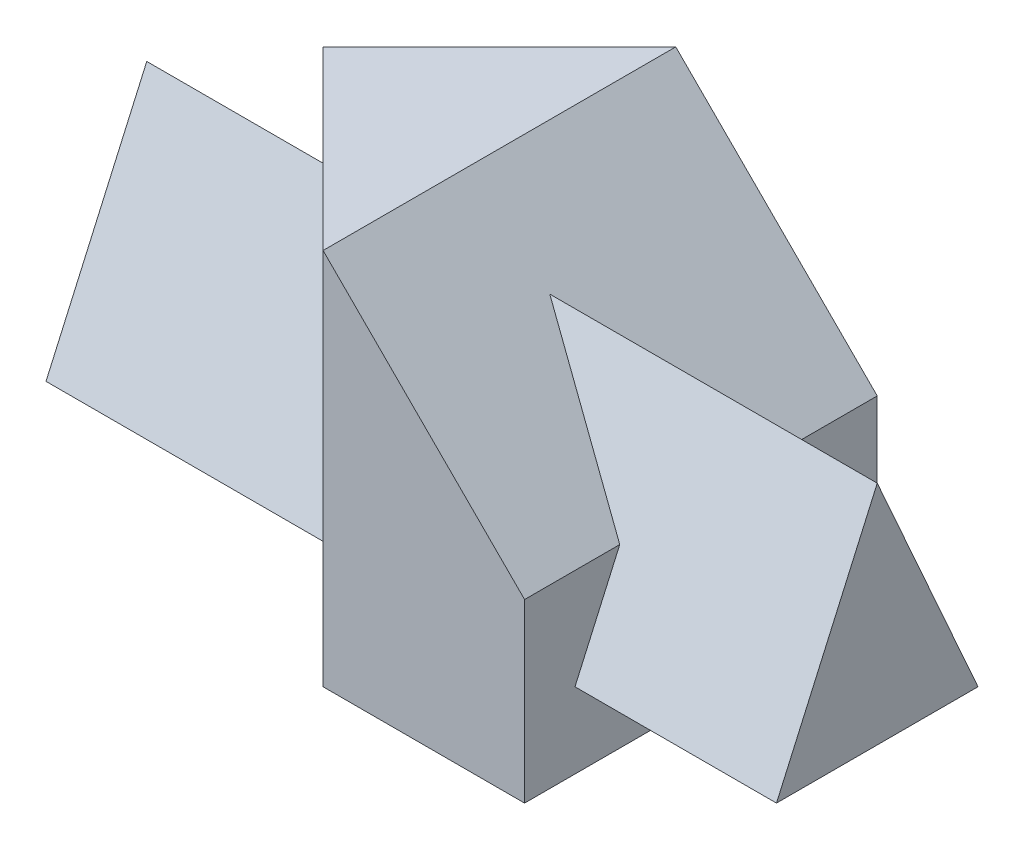
from build123d import *

# Parameters (mm, degrees)
EXTRUDE1_DEPTH      = 75
CUT_EXTRUDE1_DEPTH  = 71
EXTRUDE2_DEPTH      = 40
EXTRUDE2_DEPTH_BACK = 105


with BuildPart() as part:
    # Sketch1 → Extrude1 (new body)
    with BuildSketch(Plane(origin=(0, 0, 0), x_dir=(1, 0, 0), z_dir=(0, 1, 0))):
        Polygon((0, 0), (35, 35), (75, 35), (75, -35), (35, -35), align=None)
    extrude(amount=EXTRUDE1_DEPTH)

    # Sketch2 → Cut-Extrude1 (cut, through all)
    with BuildSketch(Plane.XY.offset(35)):
        Polygon((35, 75), (75, 35), (75, 75), align=None)
    extrude(amount=-CUT_EXTRUDE1_DEPTH, mode=Mode.SUBTRACT)

    # Sketch3 → Extrude2 (add, two sides)
    with BuildSketch(Plane(origin=(75, 0, 0), x_dir=(0, 0, -1), z_dir=(1, 0, 0))) as extrude2_sk:
        Polygon((-25, 15), (15, 15), (-5, 60), align=None)
    extrude(amount=EXTRUDE2_DEPTH)
    extrude(extrude2_sk.sketch, amount=-EXTRUDE2_DEPTH_BACK)


solid = part.part
